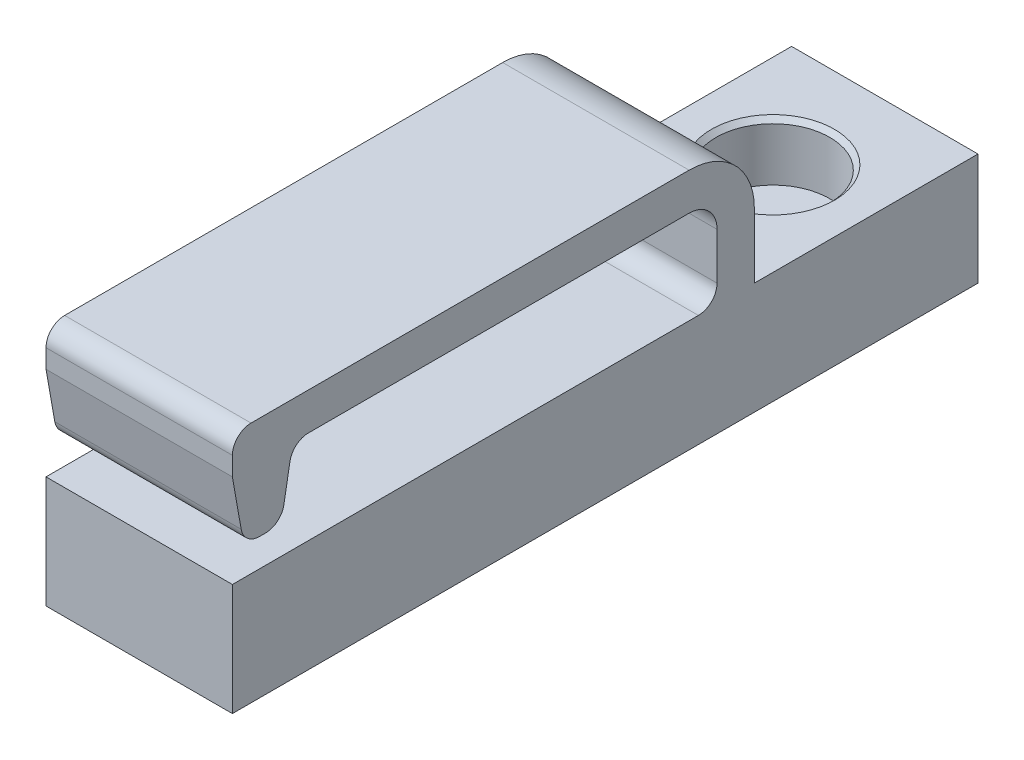
from build123d import *

# Parameters (mm, degrees)
SKETCH1_W           = 10
SKETCH1_H           = 40
BOSS_EXTRUDE1_DEPTH = 6
SKETCH2_R           = 3.05
CUT_EXTRUDE1_DEPTH  = 3.1
CHAMFER1_SIZE       = 0.25
BOSS_EXTRUDE2_DEPTH = 5
FILLET1_R           = 1.5
FILLET2_R           = 3.5
FILLET3_R           = 1
FILLET4_R           = 1


with BuildPart() as part:
    # Sketch1 → Boss-Extrude1 (new body)
    with BuildSketch(Plane(origin=(0, 0, 0), x_dir=(1, 0, 0), z_dir=(0, 1, 0))):
        with Locations((5, -20)):
            Rectangle(SKETCH1_W, SKETCH1_H)
    extrude(amount=BOSS_EXTRUDE1_DEPTH)

    # Sketch2 → Cut-Extrude1 (cut)
    with BuildSketch(Plane(origin=(0, 6, 0), x_dir=(1, 0, 0), z_dir=(0, 1, 0))):
        with Locations((5, -6)):
            Circle(SKETCH2_R)
    extrude(amount=-CUT_EXTRUDE1_DEPTH, mode=Mode.SUBTRACT)

    # Chamfer1
    chamfer1_edges = [part.edges().sort_by_distance(p)[0] for p in [
        (1.95, 6, 6),
    ]]
    chamfer(chamfer1_edges, length=CHAMFER1_SIZE)

    # Sketch4 → Boss-Extrude2 (add, symmetric)
    with BuildSketch(Plane.ZY.offset(-5)):
        Polygon((12, 6), (12, 13), (40, 13), (40, 11), (39.382855568, 7.5), (37.382855568, 7.5), (36.765711135, 11), (14, 11), (14, 6), align=None)
    extrude(amount=BOSS_EXTRUDE2_DEPTH, both=True)

    # Fillet1
    fillet1_edges = [part.edges().sort_by_distance(p)[0] for p in [
        (5, 11, 14),
    ]]
    fillet(fillet1_edges, radius=FILLET1_R)

    # Fillet2
    fillet2_edges = [part.edges().sort_by_distance(p)[0] for p in [
        (5, 13, 12),
    ]]
    fillet(fillet2_edges, radius=FILLET2_R)

    # Fillet3
    fillet3_edges = [part.edges().sort_by_distance(p)[0] for p in [
        (5, 6, 14),
    ]]
    fillet(fillet3_edges, radius=FILLET3_R)

    # Fillet4
    fillet4_edges = [part.edges().sort_by_distance(p)[0] for p in [
        (5, 11, 36.765711135),
        (5, 7.5, 37.382855568),
        (5, 7.5, 39.382855568),
        (5, 13, 40),
    ]]
    fillet(fillet4_edges, radius=FILLET4_R)


solid = part.part
